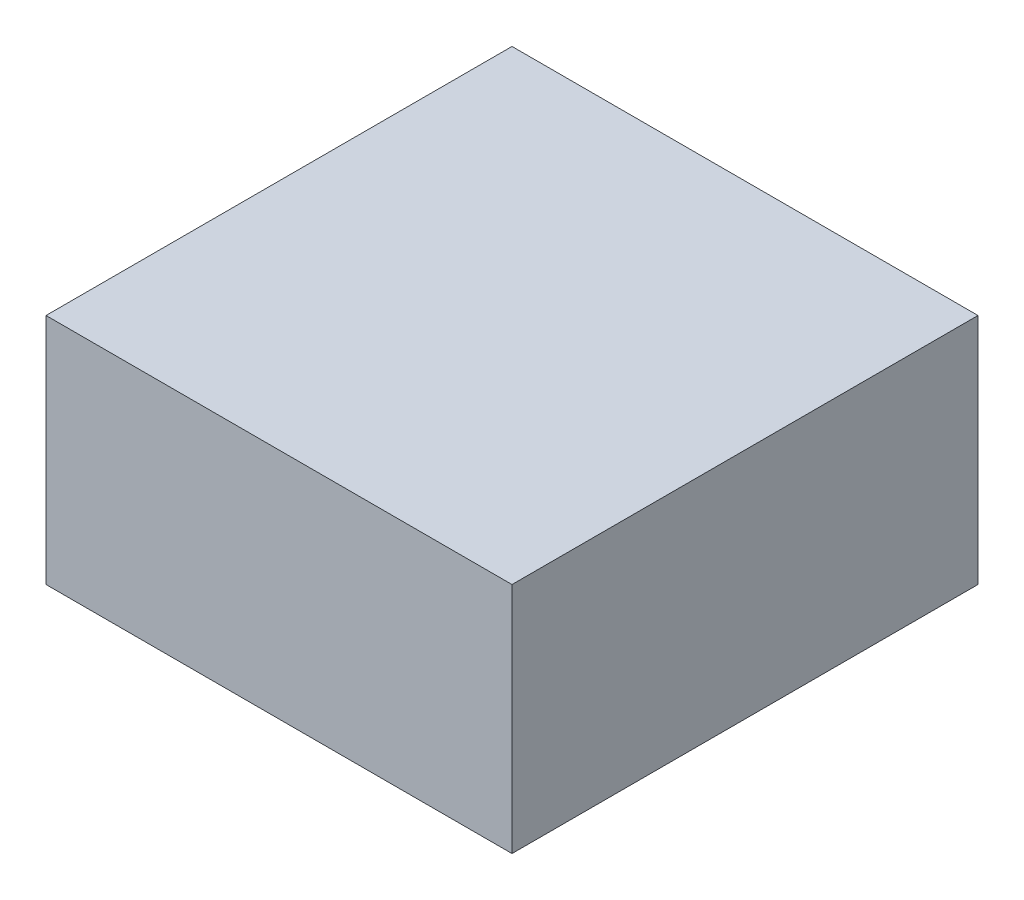
from build123d import *

# Parameters (mm, degrees)
SKETCH1_W           = 100
SKETCH1_H           = 100
BOSS_EXTRUDE1_DEPTH = 50
SKETCH3_R           = 9.07499386
CUT_EXTRUDE1_DEPTH  = 50
CUT_EXTRUDE2_DEPTH  = 10


with BuildPart() as part:
    # Sketch1 → Boss-Extrude1 (new body)
    with BuildSketch(Plane(origin=(0, 0, 0), x_dir=(1, 0, 0), z_dir=(0, 1, 0))):
        with Locations((50, -50)):
            Rectangle(SKETCH1_W, SKETCH1_H)
    extrude(amount=BOSS_EXTRUDE1_DEPTH)

    # Sketch3 → Cut-Extrude1 (cut)
    with BuildSketch(Plane.ZY):
        with Locations((32.834615457, 32.926080737)):
            Circle(SKETCH3_R)
    extrude(amount=-CUT_EXTRUDE1_DEPTH, mode=Mode.SUBTRACT)

    # Sketch7 → Cut-Extrude2 (cut)
    with BuildSketch(Plane.ZY):
        Polygon((37.189102564, 19.333333333), (38.804487179, 15.833333333), (38.463040865, 15.833333333), (37.945612981, 16.955128205), (36.358974359, 16.955128205), (35.826822917, 15.833333333), (35.483974359, 15.833333333), (37.144230769, 19.333333333), align=None)
        Polygon((37.163161058, 18.651141827), (36.529346955, 17.314102564), (37.780148237, 17.314102564), align=None, mode=Mode.SUBTRACT)
        with BuildLine():
            Line((39.253205128, 18.391025641), (39.567307692, 18.391025641))
            Line((39.567307692, 18.391025641), (39.567307692, 18.014523237))
            add(Edge.make_bspline(
                [(39.567307692, 18.014523237), (39.590496451, 18.049579066), (39.634844772, 18.116623065), (39.708557701, 18.205292366), (39.784061033, 18.278707412), (39.86171622, 18.337210931), (39.94209432, 18.38102405), (40.023431272, 18.413117085), (40.107006741, 18.4320944), (40.163168666, 18.434628059), (40.19130609, 18.435897436)],
                knots=[0, 0, 0, 0, 0.000126023, 0.000241017, 0.000345147, 0.000441342, 0.00053171, 0.000618946, 0.000702978, 0.000787349, 0.000787349, 0.000787349, 0.000787349], degree=3))
            add(Edge.make_bspline(
                [(40.19130609, 18.435897436), (40.213132416, 18.434706909), (40.258041501, 18.432257323), (40.326024091, 18.415046499), (40.396067543, 18.387568476), (40.44120993, 18.361728254), (40.46474359, 18.348257212)],
                knots=[0, 0, 0, 0, 6.5445e-05, 0.000134658, 0.00020926, 0.000290509, 0.000290509, 0.000290509, 0.000290509], degree=3))
            Line((40.46474359, 18.348257212), (40.292267628, 18.076221955))
            add(Edge.make_bspline(
                [(40.292267628, 18.076221955), (40.277158607, 18.082962221), (40.248478793, 18.095756537), (40.206524226, 18.110898547), (40.16784289, 18.119814463), (40.143199331, 18.12116518), (40.131710737, 18.121794872)],
                knots=[0, 0, 0, 0, 4.9621e-05, 9.4191e-05, 0.00013366, 0.000168129, 0.000168129, 0.000168129, 0.000168129], degree=3))
            add(Edge.make_bspline(
                [(40.131710737, 18.121794872), (40.106505004, 18.120114834), (40.055092614, 18.116688045), (39.979608114, 18.089749237), (39.906360909, 18.046223997), (39.848189246, 17.997952885), (39.803146994, 17.951405088), (39.771006768, 17.910756685), (39.741524021, 17.865178054), (39.713353801, 17.81544837), (39.687687506, 17.760718524), (39.663732837, 17.701535311), (39.642073974, 17.637830182), (39.62972373, 17.593447662), (39.623397436, 17.570713141)],
                knots=[0, 0, 0, 0, 7.549e-05, 0.000153978, 0.000237553, 0.000330197, 0.000379784, 0.000431685, 0.000485357, 0.000542493, 0.000603021, 0.000666557, 0.00073396, 0.000804745, 0.000804745, 0.000804745, 0.000804745], degree=3))
            add(Edge.make_bspline(
                [(39.623397436, 17.570713141), (39.618665043, 17.550435967), (39.608183151, 17.505523569), (39.597991613, 17.430175044), (39.587922095, 17.341151385), (39.580825477, 17.238204792), (39.574247435, 17.121592349), (39.570537352, 16.991136403), (39.567434212, 16.846703052), (39.567351145, 16.745728699), (39.567307692, 16.692908654)],
                knots=[0, 0, 0, 0, 6.2435e-05, 0.000138289, 0.000227871, 0.000331224, 0.000447781, 0.000578258, 0.000722716, 0.000881171, 0.000881171, 0.000881171, 0.000881171], degree=3))
            Line((39.567307692, 16.692908654), (39.567307692, 15.833333333))
            Line((39.567307692, 15.833333333), (39.253205128, 15.833333333))
            Line((39.253205128, 15.833333333), (39.253205128, 18.391025641))
        make_face()
        with BuildLine():
            Line((40.778846154, 19.423076923), (41.092948718, 19.423076923))
            Line((41.092948718, 19.423076923), (41.092948718, 17.907952724))
            add(Edge.make_bspline(
                [(41.092948718, 17.907952724), (41.12666602, 17.950096706), (41.192315334, 18.032153199), (41.30281145, 18.13921439), (41.416282322, 18.232013011), (41.536647132, 18.305883468), (41.661697653, 18.364240012), (41.791961297, 18.405627658), (41.927462268, 18.431078755), (42.019487418, 18.434277173), (42.066105769, 18.435897436)],
                knots=[0, 0, 0, 0, 0.000161765, 0.000314964, 0.000460595, 0.000600688, 0.000737457, 0.000873601, 0.001009745, 0.001149522, 0.001149522, 0.001149522, 0.001149522], degree=3))
            add(Edge.make_bspline(
                [(42.066105769, 18.435897436), (42.113436162, 18.434152006), (42.206073158, 18.430735778), (42.34095462, 18.403722397), (42.466915495, 18.357564958), (42.583581338, 18.294397933), (42.688406035, 18.215725106), (42.781255799, 18.124893584), (42.857096598, 18.019619665), (42.908695715, 17.922363411), (42.942269123, 17.835824657), (42.963520949, 17.761588145), (42.981540148, 17.678866232), (42.997239883, 17.5877015), (43.007703465, 17.487656328), (43.016108083, 17.379182074), (43.022084537, 17.262284956), (43.022316142, 17.181364706), (43.022435897, 17.139523237)],
                knots=[0, 0, 0, 0, 0.00014192, 0.000277771, 0.000410631, 0.000543023, 0.000674273, 0.000802678, 0.000931134, 0.001061916, 0.001131835, 0.001209267, 0.001293299, 0.001385741, 0.001486627, 0.001594927, 0.001712148, 0.001837657, 0.001837657, 0.001837657, 0.001837657], degree=3))
            Line((43.022435897, 17.139523237), (43.022435897, 15.833333333))
            Line((43.022435897, 15.833333333), (42.708333333, 15.833333333))
            Line((42.708333333, 15.833333333), (42.708333333, 17.036458333))
            add(Edge.make_bspline(
                [(42.708333333, 17.036458333), (42.70814303, 17.071281003), (42.707779013, 17.137890843), (42.706575668, 17.233256952), (42.703889453, 17.319753086), (42.699548627, 17.397102038), (42.694983319, 17.465411641), (42.688700002, 17.524582696), (42.681389768, 17.574696471), (42.674820987, 17.6048611), (42.671875, 17.618389423)],
                knots=[0, 0, 0, 0, 0.00010447, 0.000199832, 0.000286116, 0.000364054, 0.00043224, 0.000491471, 0.000542538, 0.000584064, 0.000584064, 0.000584064, 0.000584064], degree=3))
            add(Edge.make_bspline(
                [(42.671875, 17.618389423), (42.660450755, 17.658083687), (42.63848771, 17.734395677), (42.587439733, 17.838058088), (42.523680722, 17.926442828), (42.44583346, 17.998357116), (42.355275096, 18.054768656), (42.251415132, 18.093836438), (42.135231064, 18.11808416), (42.053379592, 18.120523463), (42.010717147, 18.121794872)],
                knots=[0, 0, 0, 0, 0.000123724, 0.000237858, 0.000344716, 0.000448903, 0.000553767, 0.000662748, 0.000780177, 0.000908014, 0.000908014, 0.000908014, 0.000908014], degree=3))
            add(Edge.make_bspline(
                [(42.010717147, 18.121794872), (41.985449374, 18.121319045), (41.935445104, 18.120377397), (41.861296438, 18.110923499), (41.789367375, 18.09547478), (41.718965197, 18.074570242), (41.651581999, 18.046124705), (41.585253674, 18.013194516), (41.521859465, 17.972886261), (41.460273648, 17.927660493), (41.402956115, 17.877590734), (41.349628999, 17.824743779), (41.302090659, 17.768468814), (41.259022068, 17.709668698), (41.221843783, 17.647536905), (41.189390701, 17.582672587), (41.161855004, 17.514990441), (41.148172312, 17.468015379), (41.141326122, 17.444511218)],
                knots=[0, 0, 0, 0, 7.5773e-05, 0.000149953, 0.000223797, 0.000296325, 0.00036989, 0.000442948, 0.000518233, 0.000594938, 0.000671975, 0.00074634, 0.000819955, 0.00089274, 0.000964764, 0.001036881, 0.001110181, 0.001183585, 0.001183585, 0.001183585, 0.001183585], degree=3))
            add(Edge.make_bspline(
                [(41.141326122, 17.444511218), (41.137386695, 17.427490267), (41.128802198, 17.39039952), (41.119487364, 17.329225196), (41.111149568, 17.258138824), (41.104101018, 17.177248224), (41.099777932, 17.086256981), (41.095119691, 16.985786022), (41.093385677, 16.875206002), (41.093098724, 16.798310494), (41.092948718, 16.758112981)],
                knots=[0, 0, 0, 0, 5.2397e-05, 0.000114179, 0.000185491, 0.000267122, 0.0003577, 0.000458749, 0.000568845, 0.00068944, 0.00068944, 0.00068944, 0.00068944], degree=3))
            Line((41.092948718, 16.758112981), (41.092948718, 15.833333333))
            Line((41.092948718, 15.833333333), (40.778846154, 15.833333333))
            Line((40.778846154, 15.833333333), (40.778846154, 19.423076923))
        make_face()
        with BuildLine():
            Line((46.342948718, 18.391025641), (46.342948718, 15.833333333))
            Line((46.342948718, 15.833333333), (46.028846154, 15.833333333))
            Line((46.028846154, 15.833333333), (46.028846154, 16.275741186))
            add(Edge.make_bspline(
                [(46.028846154, 16.275741186), (45.993427363, 16.235701592), (45.924307148, 16.157563821), (45.80886603, 16.055481648), (45.686497852, 15.971103327), (45.557796531, 15.902953411), (45.422878288, 15.851761355), (45.2820422, 15.815375196), (45.135230819, 15.79198136), (45.034978465, 15.789645339), (44.984174679, 15.788461538)],
                knots=[0, 0, 0, 0, 0.000160263, 0.000312755, 0.000460949, 0.000605216, 0.000748578, 0.000892786, 0.001041028, 0.001193333, 0.001193333, 0.001193333, 0.001193333], degree=3))
            add(Edge.make_bspline(
                [(44.984174679, 15.788461538), (44.939006726, 15.789687911), (44.849933521, 15.792106371), (44.718904444, 15.810868675), (44.592812194, 15.840999296), (44.471537622, 15.882900186), (44.355865476, 15.938481008), (44.244805379, 16.005022256), (44.138932687, 16.084263086), (44.039861148, 16.174851114), (43.948629148, 16.273246101), (43.868567875, 16.378191648), (43.801814796, 16.489233952), (43.745994715, 16.604967106), (43.70299837, 16.726282025), (43.673024736, 16.852759193), (43.654284289, 16.984249067), (43.651866829, 17.07378859), (43.650641026, 17.119190705)],
                knots=[0, 0, 0, 0, 0.000135464, 0.00026714, 0.000396211, 0.000523931, 0.000651257, 0.000780517, 0.000911767, 0.001047265, 0.00118272, 0.001313831, 0.001442491, 0.001570752, 0.001698704, 0.001827775, 0.001960146, 0.00209631, 0.00209631, 0.00209631, 0.00209631], degree=3))
            add(Edge.make_bspline(
                [(43.650641026, 17.119190705), (43.651893997, 17.163654409), (43.654371054, 17.251556752), (43.672824274, 17.38083545), (43.703855282, 17.505353711), (43.74740313, 17.624710654), (43.803245085, 17.739050704), (43.871173172, 17.848454729), (43.951192297, 17.953224127), (44.043444704, 18.050895353), (44.143379474, 18.141115968), (44.250288205, 18.219525013), (44.361511486, 18.287241862), (44.478774497, 18.340895338), (44.600341601, 18.384304443), (44.727295047, 18.414337411), (44.859106626, 18.432034732), (44.948597118, 18.434597496), (44.993990385, 18.435897436)],
                knots=[0, 0, 0, 0, 0.000133363, 0.00026365, 0.000390846, 0.000517716, 0.000644083, 0.000771912, 0.000903449, 0.001038867, 0.001174416, 0.001306792, 0.001436052, 0.00156435, 0.001692963, 0.001822716, 0.001954992, 0.002091156, 0.002091156, 0.002091156, 0.002091156], degree=3))
            add(Edge.make_bspline(
                [(44.993990385, 18.435897436), (45.046190244, 18.434459684), (45.148551704, 18.431640321), (45.298279713, 18.408177594), (45.439924191, 18.368539127), (45.574578543, 18.314621629), (45.701759229, 18.2429729), (45.820262213, 18.152592939), (45.931327697, 18.044051752), (45.995707988, 17.960681307), (46.028846154, 17.917768429)],
                knots=[0, 0, 0, 0, 0.00015654, 0.000306968, 0.000453261, 0.000596998, 0.000741098, 0.000889738, 0.001042937, 0.001205434, 0.001205434, 0.001205434, 0.001205434], degree=3))
            Line((46.028846154, 17.917768429), (46.028846154, 18.391025641))
            Line((46.028846154, 18.391025641), (46.342948718, 18.391025641))
        make_face()
        with BuildLine():
            add(Edge.make_bspline(
                [(44.998197115, 18.121794872), (44.952282778, 18.120161234), (44.861655178, 18.116936693), (44.728611175, 18.091763198), (44.601297761, 18.049878603), (44.480351687, 17.992596702), (44.367683471, 17.920567966), (44.2669898, 17.833446582), (44.177447098, 17.733609568), (44.102138834, 17.621507458), (44.040748337, 17.501329367), (43.997581305, 17.375704929), (43.969112058, 17.246899951), (43.966203537, 17.159537265), (43.96474359, 17.115685096)],
                knots=[0, 0, 0, 0, 0.000137677, 0.000271753, 0.000404561, 0.000538791, 0.000672205, 0.000804452, 0.00093703, 0.001073348, 0.00120849, 0.001340643, 0.001470999, 0.001602378, 0.001602378, 0.001602378, 0.001602378], degree=3))
            add(Edge.make_bspline(
                [(43.96474359, 17.115685096), (43.966608483, 17.072094989), (43.97033096, 16.985085633), (43.997081654, 16.856105056), (44.041961528, 16.730451014), (44.10320359, 16.609190021), (44.179890215, 16.49660592), (44.268778868, 16.394865798), (44.370729149, 16.30737621), (44.483656656, 16.234138636), (44.604264627, 16.174976115), (44.731098558, 16.133810476), (44.861774196, 16.107232695), (44.95062653, 16.104128218), (44.995392628, 16.102564103)],
                knots=[0, 0, 0, 0, 0.000130727, 0.000260941, 0.000393327, 0.000530037, 0.000667328, 0.000800955, 0.000934191, 0.001068956, 0.001203792, 0.001335934, 0.001468075, 0.001602253, 0.001602253, 0.001602253, 0.001602253], degree=3))
            add(Edge.make_bspline(
                [(44.995392628, 16.102564103), (45.040839131, 16.104224066), (45.131227717, 16.10752557), (45.264666425, 16.132806835), (45.394161388, 16.174575634), (45.517948617, 16.23247476), (45.633264748, 16.304232116), (45.736762625, 16.388239207), (45.824278594, 16.485942392), (45.898471203, 16.593318845), (45.95664662, 16.711030841), (45.999022679, 16.836365032), (46.024076585, 16.96932578), (46.027234315, 17.060189707), (46.028846154, 17.106570513)],
                knots=[0, 0, 0, 0, 0.000136278, 0.000271043, 0.000405851, 0.000543552, 0.000679927, 0.000812429, 0.000941985, 0.001072088, 0.00120284, 0.001334538, 0.001467925, 0.001607002, 0.001607002, 0.001607002, 0.001607002], degree=3))
            add(Edge.make_bspline(
                [(46.028846154, 17.106570513), (46.027886497, 17.141908343), (46.02599759, 17.211464377), (46.011567021, 17.313591894), (45.988612094, 17.41132562), (45.956265924, 17.504768309), (45.91377464, 17.593403325), (45.862526874, 17.677867085), (45.801621424, 17.757720296), (45.732038728, 17.831863367), (45.655873525, 17.89948983), (45.575278985, 17.95985407), (45.489300238, 18.009442843), (45.399383201, 18.050484115), (45.305371866, 18.083143264), (45.206501247, 18.104930958), (45.10382226, 18.119891279), (45.033776204, 18.12115366), (44.998197115, 18.121794872)],
                knots=[0, 0, 0, 0, 0.000105983, 0.000208608, 0.000308773, 0.00040678, 0.000504626, 0.000603105, 0.000702667, 0.00080535, 0.000907651, 0.001007914, 0.001106881, 0.00120477, 0.001304102, 0.001404791, 0.00150811, 0.001614764, 0.001614764, 0.001614764, 0.001614764], degree=3))
        make_face(mode=Mode.SUBTRACT)
        with BuildLine():
            Line((47.060897436, 18.391025641), (47.375, 18.391025641))
            Line((47.375, 18.391025641), (47.375, 17.946514423))
            add(Edge.make_bspline(
                [(47.375, 17.946514423), (47.40328395, 17.985402025), (47.45747871, 18.059914398), (47.546344362, 18.158104682), (47.635120474, 18.241432837), (47.699053856, 18.285175708), (47.729767628, 18.306189904)],
                knots=[0, 0, 0, 0, 0.000144152, 0.000276209, 0.000396804, 0.000508302, 0.000508302, 0.000508302, 0.000508302], degree=3))
            add(Edge.make_bspline(
                [(47.729767628, 18.306189904), (47.77163229, 18.326195269), (47.85463019, 18.365856482), (47.986049415, 18.406090041), (48.120524085, 18.430815143), (48.211332298, 18.434196516), (48.257011218, 18.435897436)],
                knots=[0, 0, 0, 0, 0.000139031, 0.000275633, 0.000410962, 0.000547939, 0.000547939, 0.000547939, 0.000547939], degree=3))
            add(Edge.make_bspline(
                [(48.257011218, 18.435897436), (48.287904215, 18.434852145), (48.349039794, 18.432783571), (48.439623884, 18.419323536), (48.527482495, 18.396057363), (48.612096525, 18.363650039), (48.691817204, 18.324403352), (48.764906402, 18.278353644), (48.83053061, 18.226656568), (48.888656661, 18.166977635), (48.940925687, 18.097641037), (48.989004533, 18.016776788), (49.033429746, 17.922569127), (49.058051055, 17.854202586), (49.071013622, 17.818209135)],
                knots=[0, 0, 0, 0, 9.2678e-05, 0.000183405, 0.000274048, 0.000364807, 0.000454797, 0.00054019, 0.000623517, 0.000704829, 0.000789387, 0.000883415, 0.000986597, 0.001101318, 0.001101318, 0.001101318, 0.001101318], degree=3))
            add(Edge.make_bspline(
                [(49.071013622, 17.818209135), (49.084724873, 17.842933554), (49.11170669, 17.891587739), (49.157012327, 17.960446001), (49.204480124, 18.024852793), (49.254514617, 18.084859217), (49.306939204, 18.140168948), (49.362000604, 18.190964849), (49.419385385, 18.237465063), (49.499177625, 18.291788223), (49.602990233, 18.349489404), (49.733878347, 18.399517848), (49.870028519, 18.430433976), (49.962446217, 18.434064249), (50.009114583, 18.435897436)],
                knots=[0, 0, 0, 0, 8.4789e-05, 0.000166854, 0.000247064, 0.000324714, 0.000401089, 0.000475513, 0.000549314, 0.000622436, 0.0007649, 0.000904487, 0.001041601, 0.001181469, 0.001181469, 0.001181469, 0.001181469], degree=3))
            add(Edge.make_bspline(
                [(50.009114583, 18.435897436), (50.051996046, 18.434280215), (50.135919232, 18.431115157), (50.258096498, 18.406261683), (50.372038303, 18.363584036), (50.47751538, 18.3053504), (50.572675193, 18.232171216), (50.655391502, 18.145102379), (50.725161866, 18.044759756), (50.770740505, 17.950367767), (50.801655769, 17.867032434), (50.820717004, 17.796026143), (50.837556699, 17.71787459), (50.851537944, 17.632484329), (50.861756496, 17.53955372), (50.869327212, 17.439234844), (50.874451285, 17.331449733), (50.874813358, 17.257084233), (50.875, 17.21875)],
                knots=[0, 0, 0, 0, 0.000128581, 0.000251645, 0.00037211, 0.000492305, 0.000611786, 0.000730807, 0.000851198, 0.000976936, 0.001044145, 0.001117629, 0.001197252, 0.00128393, 0.001377074, 0.001477631, 0.001585715, 0.001700707, 0.001700707, 0.001700707, 0.001700707], degree=3))
            Line((50.875, 17.21875), (50.875, 15.833333333))
            Line((50.875, 15.833333333), (50.560897436, 15.833333333))
            Line((50.560897436, 15.833333333), (50.560897436, 17.220152244))
            add(Edge.make_bspline(
                [(50.560897436, 17.220152244), (50.560819553, 17.252872818), (50.560669874, 17.315756784), (50.557976242, 17.406009236), (50.552900928, 17.488277593), (50.546966289, 17.562449681), (50.53872248, 17.628698469), (50.528076548, 17.686890888), (50.516798868, 17.737484699), (50.498062877, 17.793570747), (50.468114986, 17.855440957), (50.422497506, 17.922164533), (50.365027399, 17.980245333), (50.298667243, 18.03066365), (50.223118798, 18.071657291), (50.139854075, 18.100933301), (50.049390023, 18.119056179), (49.986767235, 18.120862195), (49.954427083, 18.121794872)],
                knots=[0, 0, 0, 0, 9.816e-05, 0.000188648, 0.000270826, 0.000345412, 0.000411852, 0.000470988, 0.000522857, 0.0005672, 0.000648106, 0.000728233, 0.000808554, 0.000892128, 0.000977461, 0.001065278, 0.001156029, 0.001252946, 0.001252946, 0.001252946, 0.001252946], degree=3))
            add(Edge.make_bspline(
                [(49.954427083, 18.121794872), (49.914757129, 18.120378714), (49.836354218, 18.117579849), (49.721908732, 18.089005976), (49.611937715, 18.045925725), (49.509722582, 17.983493268), (49.415694791, 17.908684904), (49.334795214, 17.819735309), (49.267963028, 17.719105382), (49.222709052, 17.625958679), (49.194119751, 17.542289236), (49.175242835, 17.469191864), (49.160559444, 17.386110296), (49.146788914, 17.293602805), (49.137801186, 17.191032624), (49.129632814, 17.078874223), (49.125811951, 16.956790264), (49.125277492, 16.872163575), (49.125, 16.82822516)],
                knots=[0, 0, 0, 0, 0.000118788, 0.00023477, 0.000351815, 0.000471937, 0.000592603, 0.000711217, 0.000831002, 0.000953929, 0.001020668, 0.001096002, 0.00118016, 0.001273662, 0.001376495, 0.001488939, 0.001611007, 0.001742825, 0.001742825, 0.001742825, 0.001742825], degree=3))
            Line((49.125, 16.82822516), (49.125, 15.833333333))
            Line((49.125, 15.833333333), (48.810897436, 15.833333333))
            Line((48.810897436, 15.833333333), (48.810897436, 17.133914263))
            add(Edge.make_bspline(
                [(48.810897436, 17.133914263), (48.810818005, 17.170607582), (48.810665188, 17.241201839), (48.80798887, 17.342435514), (48.802902249, 17.434516594), (48.7970217, 17.517338058), (48.788561522, 17.590749387), (48.77895176, 17.655144145), (48.767603149, 17.710360896), (48.748813265, 17.770924281), (48.720098796, 17.837645204), (48.673910534, 17.908786225), (48.616302954, 17.971054322), (48.548732078, 18.024213071), (48.472726396, 18.068154552), (48.388742995, 18.099814304), (48.297538082, 18.118238594), (48.234660376, 18.12058709), (48.202323718, 18.121794872)],
                knots=[0, 0, 0, 0, 0.000110078, 0.00021178, 0.000303758, 0.00038673, 0.000460827, 0.00052538, 0.000582037, 0.000629718, 0.00071543, 0.000799052, 0.000882908, 0.000968755, 0.001056067, 0.001145266, 0.001236843, 0.001333803, 0.001333803, 0.001333803, 0.001333803], degree=3))
            add(Edge.make_bspline(
                [(48.202323718, 18.121794872), (48.164307506, 18.120264412), (48.088542547, 18.117214259), (47.977240577, 18.089759985), (47.869754894, 18.046755911), (47.767800195, 17.987096092), (47.674126047, 17.913197013), (47.592117779, 17.826282117), (47.523175254, 17.727433084), (47.477443439, 17.635268567), (47.447944965, 17.553695292), (47.42834963, 17.484344345), (47.411510004, 17.407344096), (47.398995983, 17.322456985), (47.386915567, 17.230235891), (47.381085258, 17.130221401), (47.375413696, 17.022499314), (47.375141281, 16.948126768), (47.375, 16.909555288)],
                knots=[0, 0, 0, 0, 0.000113893, 0.000226985, 0.000341817, 0.000460265, 0.000580056, 0.000698595, 0.000817435, 0.000940348, 0.001005999, 0.001077458, 0.001156396, 0.001242271, 0.001334801, 0.001435306, 0.00154269, 0.001658383, 0.001658383, 0.001658383, 0.001658383], degree=3))
            Line((47.375, 16.909555288), (47.375, 15.833333333))
            Line((47.375, 15.833333333), (47.060897436, 15.833333333))
            Line((47.060897436, 15.833333333), (47.060897436, 18.391025641))
        make_face()
        Polygon((53.028846154, 19.333333333), (53.477564103, 19.333333333), (53.477564103, 18.048878205), (54.783754006, 19.333333333), (55.33974359, 19.333333333), (53.661258013, 17.761418269), (55.474358974, 15.833333333), (54.945713141, 15.833333333), (53.477564103, 17.473958333), (53.477564103, 15.833333333), (53.028846154, 15.833333333), align=None)
        with BuildLine():
            Line((55.855769231, 19.423076923), (56.304487179, 19.423076923))
            Line((56.304487179, 19.423076923), (56.304487179, 17.962640224))
            add(Edge.make_bspline(
                [(56.304487179, 17.962640224), (56.311562847, 17.983131489), (56.325500573, 18.023495403), (56.353245261, 18.080860405), (56.386560436, 18.134516254), (56.424711264, 18.184656069), (56.468384484, 18.230937374), (56.516835358, 18.273802053), (56.570807419, 18.31307101), (56.649667718, 18.359226596), (56.753948328, 18.408870171), (56.886567269, 18.44947499), (57.024166991, 18.476253315), (57.117894326, 18.479248867), (57.165464744, 18.480769231)],
                knots=[0, 0, 0, 0, 6.4993e-05, 0.000128024, 0.000190675, 0.000254199, 0.000316697, 0.000381269, 0.000448023, 0.000516561, 0.000655194, 0.000793343, 0.000931683, 0.001074259, 0.001074259, 0.001074259, 0.001074259], degree=3))
            add(Edge.make_bspline(
                [(57.165464744, 18.480769231), (57.191665446, 18.48051406), (57.243485372, 18.480009382), (57.319966245, 18.471491541), (57.394437251, 18.460356591), (57.46591439, 18.442246532), (57.535518735, 18.42076111), (57.602269336, 18.393138556), (57.667431966, 18.361948434), (57.72866839, 18.32428919), (57.787388099, 18.28406544), (57.842242168, 18.240508665), (57.892782039, 18.19407687), (57.939620008, 18.14516108), (57.980400596, 18.091986243), (58.019203469, 18.037554221), (58.051367148, 17.978877823), (58.082042889, 17.917920439), (58.10713136, 17.85056402), (58.129770866, 17.776474072), (58.147391986, 17.693786741), (58.162966518, 17.603314519), (58.174648123, 17.504543113), (58.182669665, 17.397636107), (58.188780274, 17.282621544), (58.188992675, 17.203100602), (58.189102564, 17.161959135)],
                knots=[0, 0, 0, 0, 7.8554e-05, 0.000155364, 0.000230633, 0.000304264, 0.00037633, 0.00044898, 0.000520785, 0.00059281, 0.00066438, 0.000734239, 0.00080272, 0.000870173, 0.000937078, 0.001003592, 0.001070468, 0.00113757, 0.001208144, 0.001285776, 0.001369808, 0.001461558, 0.001561132, 0.001668035, 0.001783155, 0.001906561, 0.001906561, 0.001906561, 0.001906561], degree=3))
            Line((58.189102564, 17.161959135), (58.189102564, 15.833333333))
            Line((58.189102564, 15.833333333), (57.740384615, 15.833333333))
            Line((57.740384615, 15.833333333), (57.740384615, 17.058193109))
            add(Edge.make_bspline(
                [(57.740384615, 17.058193109), (57.740184936, 17.091613106), (57.739802318, 17.155651444), (57.738718512, 17.247284523), (57.735667333, 17.330245904), (57.732491588, 17.404368898), (57.727733049, 17.469860222), (57.721280264, 17.526633035), (57.714757466, 17.57490153), (57.708738745, 17.603923877), (57.706029647, 17.616987179)],
                knots=[0, 0, 0, 0, 0.000100263, 0.000192121, 0.0002749, 0.000349302, 0.000414691, 0.000471831, 0.000520714, 0.000560727, 0.000560727, 0.000560727, 0.000560727], degree=3))
            add(Edge.make_bspline(
                [(57.706029647, 17.616987179), (57.69561934, 17.653339367), (57.675615194, 17.723192684), (57.62997779, 17.818479215), (57.571505902, 17.898603871), (57.501603964, 17.964607262), (57.419612933, 18.015766941), (57.325587027, 18.051543351), (57.220000381, 18.073577975), (57.145480957, 18.075775589), (57.106570513, 18.076923077)],
                knots=[0, 0, 0, 0, 0.000113307, 0.000217727, 0.000315049, 0.000409292, 0.00050442, 0.000602982, 0.000709686, 0.000826283, 0.000826283, 0.000826283, 0.000826283], degree=3))
            add(Edge.make_bspline(
                [(57.106570513, 18.076923077), (57.085504843, 18.076410155), (57.043671506, 18.075391567), (56.981808923, 18.066422696), (56.921170232, 18.053397918), (56.861864019, 18.034123879), (56.803637464, 18.009615557), (56.746622343, 17.979334084), (56.691215579, 17.943125236), (56.636930243, 17.902868577), (56.584941709, 17.858516499), (56.53828531, 17.809029996), (56.495065979, 17.757039983), (56.456473114, 17.701394236), (56.422084096, 17.642630168), (56.392417871, 17.580207051), (56.367210457, 17.514523289), (56.353947078, 17.468920427), (56.347255609, 17.445913462)],
                knots=[0, 0, 0, 0, 6.3163e-05, 0.000125433, 0.000187183, 0.000249045, 0.000312201, 0.000376498, 0.000442426, 0.000510575, 0.000579171, 0.000647107, 0.000714345, 0.000781835, 0.000850018, 0.000918383, 0.000988957, 0.001060814, 0.001060814, 0.001060814, 0.001060814], degree=3))
            add(Edge.make_bspline(
                [(56.347255609, 17.445913462), (56.343843778, 17.430517271), (56.33628342, 17.396400482), (56.327270779, 17.339797293), (56.32092231, 17.272793461), (56.314084807, 17.195484396), (56.310675563, 17.107515439), (56.306839135, 17.009376361), (56.304864878, 16.900915676), (56.30461715, 16.82518743), (56.304487179, 16.785456731)],
                knots=[0, 0, 0, 0, 4.7304e-05, 0.000104821, 0.000171796, 0.000249177, 0.000337618, 0.000435838, 0.000543831, 0.000663024, 0.000663024, 0.000663024, 0.000663024], degree=3))
            Line((56.304487179, 16.785456731), (56.304487179, 15.833333333))
            Line((56.304487179, 15.833333333), (55.855769231, 15.833333333))
            Line((55.855769231, 15.833333333), (55.855769231, 19.423076923))
        make_face()
        with BuildLine():
            Line((61.509615385, 18.435897436), (61.509615385, 15.833333333))
            Line((61.509615385, 15.833333333), (61.060897436, 15.833333333))
            Line((61.060897436, 15.833333333), (61.060897436, 16.267327724))
            add(Edge.make_bspline(
                [(61.060897436, 16.267327724), (61.052920891, 16.248647385), (61.036908227, 16.211147193), (61.004885151, 16.15870835), (60.967413256, 16.109049324), (60.923822415, 16.06285696), (60.874449328, 16.019979729), (60.819381514, 15.980395094), (60.758018665, 15.944943135), (60.66905438, 15.901044695), (60.550090533, 15.855507175), (60.399662832, 15.817462708), (60.242586966, 15.792440301), (60.135280656, 15.789802514), (60.080729167, 15.788461538)],
                knots=[0, 0, 0, 0, 6.0869e-05, 0.000122192, 0.000183751, 0.00024724, 0.000312339, 0.000379661, 0.000450367, 0.000524679, 0.000677152, 0.000831389, 0.000989546, 0.001153089, 0.001153089, 0.001153089, 0.001153089], degree=3))
            add(Edge.make_bspline(
                [(60.080729167, 15.788461538), (60.034863856, 15.789702982), (59.944401747, 15.792151533), (59.811185889, 15.81071083), (59.683235827, 15.841596462), (59.560245004, 15.88451503), (59.442558237, 15.940295088), (59.330123933, 16.008570165), (59.223128932, 16.089226489), (59.122159545, 16.180219458), (59.03030625, 16.280593092), (58.948998856, 16.387300428), (58.880943613, 16.500141178), (58.824178777, 16.617766788), (58.780566826, 16.741220373), (58.749854643, 16.869998346), (58.731210486, 17.00412858), (58.728792859, 17.095292592), (58.727564103, 17.141626603)],
                knots=[0, 0, 0, 0, 0.000137565, 0.000271325, 0.000402605, 0.00053188, 0.000661407, 0.000792592, 0.000925805, 0.001062813, 0.001199774, 0.001333409, 0.001464594, 0.001594423, 0.001724592, 0.001856553, 0.001991008, 0.002129974, 0.002129974, 0.002129974, 0.002129974], degree=3))
            add(Edge.make_bspline(
                [(58.727564103, 17.141626603), (58.72873034, 17.186804244), (58.731037038, 17.276160948), (58.750759729, 17.407363609), (58.781096086, 17.534039252), (58.82599424, 17.654989177), (58.882165591, 17.771464773), (58.951418144, 17.882737059), (59.033308616, 17.988949703), (59.126399071, 18.089056489), (59.228689849, 18.179821164), (59.336427829, 18.260698678), (59.449588928, 18.328939604), (59.567969078, 18.384721081), (59.691658744, 18.427641588), (59.820084918, 18.458440063), (59.953745551, 18.477125548), (60.044444405, 18.479541334), (60.090544872, 18.480769231)],
                knots=[0, 0, 0, 0, 0.000135464, 0.000267933, 0.00039717, 0.000525597, 0.000654163, 0.000784519, 0.000918021, 0.001055934, 0.001193986, 0.00132776, 0.001459545, 0.001589707, 0.001719643, 0.001851605, 0.001985365, 0.00212363, 0.00212363, 0.00212363, 0.00212363], degree=3))
            add(Edge.make_bspline(
                [(60.090544872, 18.480769231), (60.146273135, 18.479250981), (60.255519019, 18.476274709), (60.415098436, 18.449972372), (60.567121987, 18.409076091), (60.686360698, 18.359989041), (60.775157109, 18.313188113), (60.835276057, 18.274846596), (60.889495442, 18.233322544), (60.936308554, 18.187521163), (60.977584762, 18.138943455), (61.012055762, 18.086656246), (61.040658403, 18.03100961), (61.054126179, 17.991579347), (61.060897436, 17.971754808)],
                knots=[0, 0, 0, 0, 0.000167079, 0.00032753, 0.000483844, 0.000638524, 0.000713173, 0.000784746, 0.000852203, 0.000917652, 0.00098085, 0.001043076, 0.00110516, 0.001167937, 0.001167937, 0.001167937, 0.001167937], degree=3))
            Line((61.060897436, 17.971754808), (61.060897436, 18.435897436))
            Line((61.060897436, 18.435897436), (61.509615385, 18.435897436))
        make_face()
        with BuildLine():
            add(Edge.make_bspline(
                [(60.09755609, 18.076923077), (60.057957345, 18.075660003), (59.979549028, 18.073159029), (59.864251554, 18.050559209), (59.753051093, 18.013803147), (59.646880726, 17.962537485), (59.546565946, 17.898365882), (59.456308667, 17.818598907), (59.375146339, 17.726091859), (59.304961743, 17.62148323), (59.247659148, 17.508351244), (59.206512459, 17.388786674), (59.181228635, 17.264918662), (59.177936845, 17.180538956), (59.176282051, 17.138120994)],
                knots=[0, 0, 0, 0, 0.000118697, 0.000235028, 0.000350985, 0.000469209, 0.000587837, 0.000707086, 0.000829302, 0.000956089, 0.001084018, 0.001208629, 0.001334442, 0.001461624, 0.001461624, 0.001461624, 0.001461624], degree=3))
            add(Edge.make_bspline(
                [(59.176282051, 17.138120994), (59.177919813, 17.095699892), (59.181168867, 17.011543282), (59.206706215, 16.887431524), (59.248213687, 16.767338851), (59.306551206, 16.653215804), (59.377092535, 16.54769467), (59.458352323, 16.453832811), (59.549557391, 16.374091092), (59.649193351, 16.307774493), (59.755882152, 16.25727852), (59.865743485, 16.219290111), (59.979344287, 16.197036023), (60.056096209, 16.193891435), (60.094751603, 16.192307692)],
                knots=[0, 0, 0, 0, 0.000127182, 0.000252308, 0.000378473, 0.000507344, 0.000635685, 0.00075843, 0.000878668, 0.000998064, 0.001116288, 0.001231803, 0.001346069, 0.001462011, 0.001462011, 0.001462011, 0.001462011], degree=3))
            add(Edge.make_bspline(
                [(60.094751603, 16.192307692), (60.137390259, 16.193764465), (60.221904025, 16.196651922), (60.346880341, 16.220686067), (60.467694251, 16.260301379), (60.583997659, 16.314005957), (60.691631774, 16.381381375), (60.78838199, 16.460073744), (60.870202001, 16.551205637), (60.939510774, 16.651518407), (60.993163057, 16.761428021), (61.033000474, 16.877867017), (61.056665093, 17.001382987), (61.059467974, 17.085901946), (61.060897436, 17.12900641)],
                knots=[0, 0, 0, 0, 0.000127837, 0.000253385, 0.000380208, 0.000508506, 0.000636706, 0.000760231, 0.000881344, 0.001002889, 0.001124862, 0.001247029, 0.001371199, 0.001500435, 0.001500435, 0.001500435, 0.001500435], degree=3))
            add(Edge.make_bspline(
                [(61.060897436, 17.12900641), (61.060167957, 17.162005237), (61.058728677, 17.227112771), (61.045003169, 17.322447209), (61.023113272, 17.41372066), (60.993371615, 17.500998228), (60.953246706, 17.583533438), (60.905924015, 17.662551521), (60.848144002, 17.736338111), (60.783596064, 17.805986227), (60.712505904, 17.869423209), (60.636805765, 17.925100084), (60.556516752, 17.971739253), (60.472633927, 18.010561008), (60.384248169, 18.03966276), (60.292464716, 18.06199704), (60.196294124, 18.07450343), (60.130776467, 18.076108988), (60.09755609, 18.076923077)],
                knots=[0, 0, 0, 0, 9.8948e-05, 0.000195226, 0.000288246, 0.000380264, 0.000471207, 0.000563073, 0.00065605, 0.000751796, 0.000847635, 0.000941452, 0.001033202, 0.001125753, 0.001218208, 0.00131191, 0.001408789, 0.001508437, 0.001508437, 0.001508437, 0.001508437], degree=3))
        make_face(mode=Mode.SUBTRACT)
        with BuildLine():
            Line((62.227564103, 18.435897436), (62.676282051, 18.435897436))
            Line((62.676282051, 18.435897436), (62.676282051, 17.982972756))
            add(Edge.make_bspline(
                [(62.676282051, 17.982972756), (62.683155235, 18.00321348), (62.696755296, 18.043264069), (62.72346064, 18.100317695), (62.756061614, 18.153354209), (62.793973143, 18.20240769), (62.837020677, 18.247730214), (62.885740106, 18.288591674), (62.940116906, 18.32487974), (63.018749208, 18.368754132), (63.124499702, 18.413091654), (63.256985653, 18.452627316), (63.395476428, 18.476511607), (63.489490081, 18.479334754), (63.537259615, 18.480769231)],
                knots=[0, 0, 0, 0, 6.4094e-05, 0.000126824, 0.000188511, 0.000250496, 0.000312485, 0.000375683, 0.000440827, 0.000508313, 0.000645577, 0.000783784, 0.000922446, 0.001065683, 0.001065683, 0.001065683, 0.001065683], degree=3))
            add(Edge.make_bspline(
                [(63.537259615, 18.480769231), (63.563460318, 18.48051406), (63.615280244, 18.480009382), (63.691761115, 18.471491539), (63.766232128, 18.460356596), (63.837709243, 18.442246515), (63.907313676, 18.420761172), (63.974063949, 18.393138326), (64.039227793, 18.361949284), (64.10045969, 18.324286017), (64.159196072, 18.28407708), (64.213989832, 18.240466721), (64.264874519, 18.194114129), (64.31089035, 18.144482845), (64.352732887, 18.091916826), (64.390489607, 18.036994991), (64.423609817, 17.978656222), (64.4536097, 17.91733539), (64.478963782, 17.849885421), (64.501660521, 17.775556401), (64.51909483, 17.692598395), (64.534715359, 17.602141601), (64.546491944, 17.503613953), (64.554454877, 17.396933975), (64.560566394, 17.282154184), (64.560784768, 17.202866907), (64.560897436, 17.161959135)],
                knots=[0, 0, 0, 0, 7.8554e-05, 0.000155364, 0.000230633, 0.000304264, 0.00037633, 0.00044898, 0.000520785, 0.00059281, 0.00066438, 0.000734239, 0.00080272, 0.000870685, 0.00093704, 0.001004132, 0.001070398, 0.001138132, 0.001208705, 0.001286337, 0.001371054, 0.001462804, 0.001561682, 0.001668584, 0.001783705, 0.001906409, 0.001906409, 0.001906409, 0.001906409], degree=3))
            Line((64.560897436, 17.161959135), (64.560897436, 15.833333333))
            Line((64.560897436, 15.833333333), (64.112179487, 15.833333333))
            Line((64.112179487, 15.833333333), (64.112179487, 17.058193109))
            add(Edge.make_bspline(
                [(64.112179487, 17.058193109), (64.111976035, 17.091612789), (64.111586187, 17.155650519), (64.110551504, 17.247287729), (64.107339982, 17.330235624), (64.104671782, 17.404420145), (64.098339909, 17.469773536), (64.093252871, 17.526667424), (64.086721039, 17.574989107), (64.080106459, 17.603933676), (64.077123397, 17.616987179)],
                knots=[0, 0, 0, 0, 0.000100263, 0.000192121, 0.0002749, 0.000349302, 0.000414747, 0.000471814, 0.000520697, 0.000560851, 0.000560851, 0.000560851, 0.000560851], degree=3))
            add(Edge.make_bspline(
                [(64.077123397, 17.616987179), (64.067483871, 17.653575741), (64.049016303, 17.723672729), (64.004615681, 17.81925357), (63.946775887, 17.899437385), (63.877079157, 17.965372955), (63.794527153, 18.015808394), (63.700184463, 18.051562634), (63.594117471, 18.073521209), (63.519375685, 18.075758469), (63.48046875, 18.076923077)],
                knots=[0, 0, 0, 0, 0.000113359, 0.000217174, 0.000314084, 0.000408327, 0.000503085, 0.0006023, 0.000709691, 0.000826288, 0.000826288, 0.000826288, 0.000826288], degree=3))
            add(Edge.make_bspline(
                [(63.48046875, 18.076923077), (63.459402071, 18.076414999), (63.417566731, 18.075406031), (63.355492706, 18.066332919), (63.294578681, 18.053507826), (63.235049197, 18.034139105), (63.176699844, 18.009430674), (63.11923846, 17.979548787), (63.063722895, 17.943099648), (63.009436854, 17.902864634), (62.957383614, 17.858558464), (62.910881798, 17.808759389), (62.866705959, 17.757510275), (62.829115457, 17.701126574), (62.794522417, 17.642671507), (62.764929808, 17.580195623), (62.739702326, 17.514526245), (62.726441688, 17.468921418), (62.719751603, 17.445913462)],
                knots=[0, 0, 0, 0, 6.3163e-05, 0.000125433, 0.000187868, 0.00024973, 0.000312886, 0.000377803, 0.000443731, 0.00051188, 0.000580476, 0.000648412, 0.000716098, 0.00078319, 0.000851372, 0.000919738, 0.000990312, 0.001062169, 0.001062169, 0.001062169, 0.001062169], degree=3))
            add(Edge.make_bspline(
                [(62.719751603, 17.445913462), (62.715978818, 17.430070768), (62.707662368, 17.395148299), (62.700457037, 17.337068402), (62.692026002, 17.269403113), (62.687291703, 17.191659801), (62.682030177, 17.1040507), (62.678768571, 17.006563265), (62.676629275, 16.899282263), (62.676401113, 16.824487168), (62.676282051, 16.785456731)],
                knots=[0, 0, 0, 0, 4.8822e-05, 0.000107621, 0.000175369, 0.000253395, 0.000341173, 0.000438692, 0.000545984, 0.000663073, 0.000663073, 0.000663073, 0.000663073], degree=3))
            Line((62.676282051, 16.785456731), (62.676282051, 15.833333333))
            Line((62.676282051, 15.833333333), (62.227564103, 15.833333333))
            Line((62.227564103, 15.833333333), (62.227564103, 18.435897436))
        make_face()
    extrude(amount=-CUT_EXTRUDE2_DEPTH, mode=Mode.SUBTRACT)


solid = part.part
